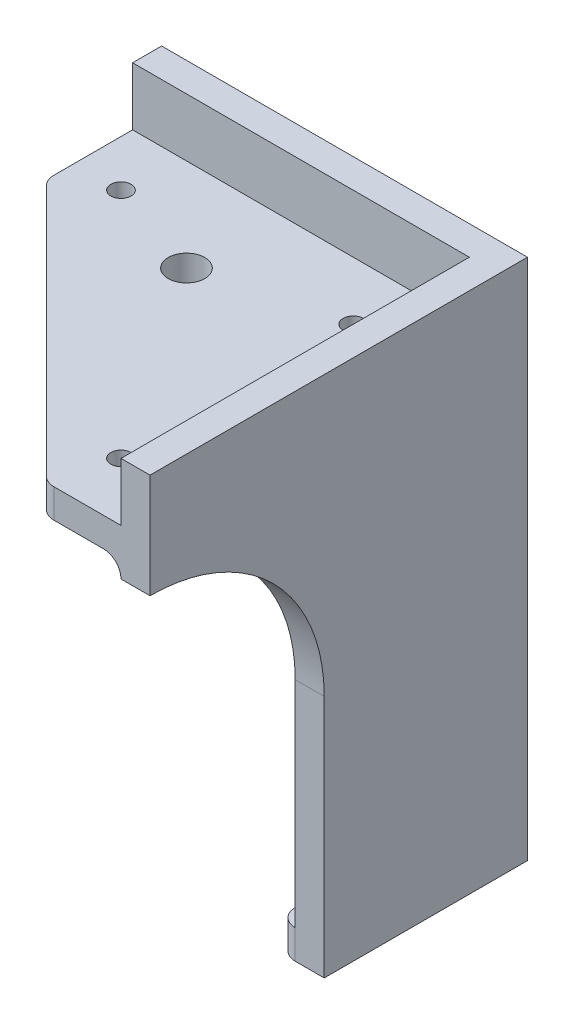
from build123d import *

# Parameters (mm, degrees)
SALIENTE_EXTRUIR1_DEPTH = 5
CROQUIS2_W              = 5
CROQUIS2_H              = 90
SALIENTE_EXTRUIR2_DEPTH = 60
CORTAR_EXTRUIR1_DEPTH   = 5
SALIENTE_EXTRUIR3_DEPTH = 5
REDONDEO1_R             = 3
CROQUIS5_W              = 58
CROQUIS5_H              = 5
SALIENTE_EXTRUIR4_DEPTH = 60
CORTAR_EXTRUIR2_DEPTH   = 5
REDONDEO2_R             = 3
REDONDEO3_R             = 3
CROQUIS7_R              = 1.75
CROQUIS7_R_2            = 3.15
CORTAR_EXTRUIR3_DEPTH   = 5


with BuildPart() as part:
    # Croquis1 → Saliente-Extruir1 (new body)
    with BuildSketch(Plane.XY):
        with BuildLine():
            Line((-63, 0), (0, 0))
            Line((0, 0), (0, -90))
            Line((0, -90), (-33, -90))
            Line((-33, -90), (-33, -48))
            ThreePointArc((-33, -48), (-41.786797, -26.786797), (-63, -18))
            Line((-63, -18), (-63, 0))
        make_face()
    extrude(amount=SALIENTE_EXTRUIR1_DEPTH)

    # Croquis2 → Saliente-Extruir2 (add)
    with BuildSketch(Plane.XY.offset(5)):
        with Locations((-2.5, -45)):
            Rectangle(CROQUIS2_W, CROQUIS2_H)
    extrude(amount=SALIENTE_EXTRUIR2_DEPTH)

    # Croquis3 → Cortar-Extruir1 (cut)
    with BuildSketch(Plane(origin=(0, 0, 0), x_dir=(0, 0, -1), z_dir=(1, 0, 0))):
        with BuildLine():
            Line((-65, -90), (-35, -90))
            Line((-35, -90), (-35, -48))
            ThreePointArc((-35, -48), (-43.786797, -26.786797), (-65, -18))
            Line((-65, -18), (-65, -90))
        make_face()
    extrude(amount=-CORTAR_EXTRUIR1_DEPTH, mode=Mode.SUBTRACT)

    # Croquis4 → Saliente-Extruir3 (add)
    with BuildSketch(Plane.XZ.offset(90)):
        Polygon((-33, 8), (-8, 8), (-8, 35), (-5, 35), (-5, 5), (-33, 5), align=None)
    extrude(amount=-SALIENTE_EXTRUIR3_DEPTH)

    # Redondeo1
    redondeo1_edges = [part.edges().sort_by_distance(p)[0] for p in [
        (-33, -87.5, 8),
        (-8, -87.5, 35),
    ]]
    fillet(redondeo1_edges, radius=REDONDEO1_R)

    # Croquis5 → Saliente-Extruir4 (add)
    with BuildSketch(Plane.XY.offset(5)):
        with Locations((-34, -12.5)):
            Rectangle(CROQUIS5_W, CROQUIS5_H)
    extrude(amount=SALIENTE_EXTRUIR4_DEPTH)

    # Croquis6 → Cortar-Extruir2 (cut)
    with BuildSketch(Plane(origin=(0, -10, 0), x_dir=(1, 0, 0), z_dir=(0, 1, 0))):
        Polygon((-63, -19.817641), (-17.817641, -65), (-63, -65), align=None)
    extrude(amount=-CORTAR_EXTRUIR2_DEPTH, mode=Mode.SUBTRACT)

    # Redondeo2
    redondeo2_edges = [part.edges().sort_by_distance(p)[0] for p in [
        (-63, -12.5, 19.817641),
        (-17.817641, -12.5, 65),
    ]]
    fillet(redondeo2_edges, radius=REDONDEO2_R)

    # Redondeo3
    redondeo3_edges = [part.edges().sort_by_distance(p)[0] for p in [
        (-34, -15, 5),
        (-5, -15, 35),
        (-5, -50, 5),
    ]]
    fillet(redondeo3_edges, radius=REDONDEO3_R)

    # Croquis7 → Cortar-Extruir3 (cut)
    with BuildSketch(Plane(origin=(0, -10, 0), x_dir=(1, 0, 0), z_dir=(0, 1, 0))):
        with Locations((-15, -55)):
            Circle(CROQUIS7_R)
        with Locations((-15, -15)):
            Circle(CROQUIS7_R)
        with Locations((-55, -15)):
            Circle(CROQUIS7_R)
        with Locations((-37.744345, -20.975)):
            Circle(CROQUIS7_R_2)
    extrude(amount=-CORTAR_EXTRUIR3_DEPTH, mode=Mode.SUBTRACT)


solid = part.part
